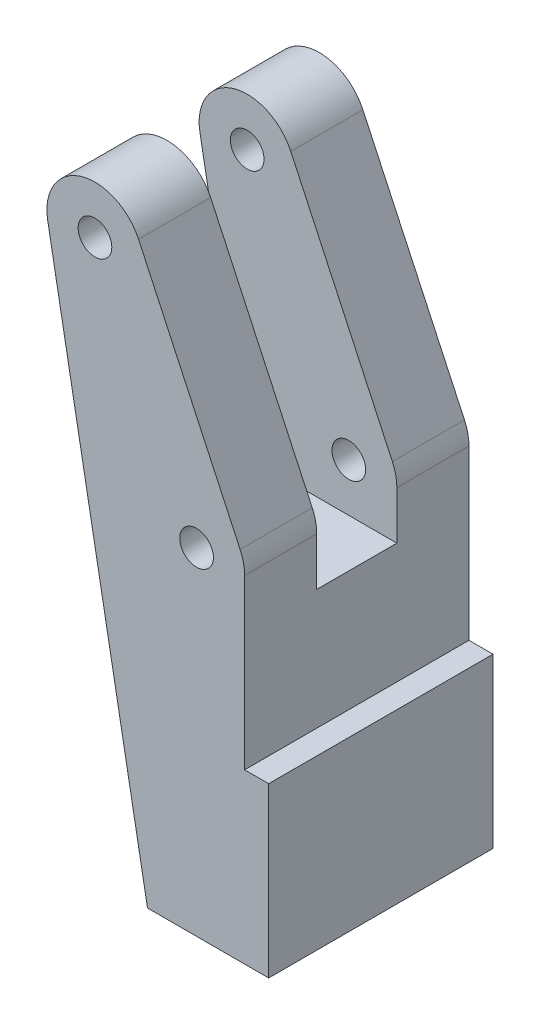
from build123d import *

# Parameters (mm, degrees)
SKETCH1_R           = 1.75
BOSS_EXTRUDE1_DEPTH = 7.5
BOSS_EXTRUDE2_DEPTH = 8.333333333
SKETCH3_R           = 1.75
BOSS_EXTRUDE4_DEPTH = 7.5
SKETCH4_W           = 23.333333333
SKETCH4_H           = 17.5
BOSS_EXTRUDE5_DEPTH = 2.5


with BuildPart() as part:
    # Sketch1 → Boss-Extrude1 (new body)
    with BuildSketch(Plane.XY):
        with BuildLine():
            Line((-6.033917608, 24.770785985), (4.531538935, 2.113091309))
            ThreePointArc((4.531538935, 2.113091309), (4.881480036, 1.08219807), (5, 0))
            Line((5, 0), (5, -35))
            Line((5, -35), (-5.1028501, -35))
            Line((-5.1028501, -35), (-15.483867589, 21.758121008))
            ThreePointArc((-15.483867589, 21.758121008), (-12.084158316, 27.421468907), (-6.033917608, 24.770785985))
        make_face()
        with Locations((-10.565456544, 22.657694676)):
            Circle(SKETCH1_R, mode=Mode.SUBTRACT)
        Circle(SKETCH1_R, mode=Mode.SUBTRACT)
    extrude(amount=BOSS_EXTRUDE1_DEPTH)

    # Sketch2 → Boss-Extrude2 (add)
    with BuildSketch(Plane.XY.offset(7.5)):
        Polygon((5, -5), (-10.589827455, -5), (-5.1028501, -35), (5, -35), align=None)
    extrude(amount=BOSS_EXTRUDE2_DEPTH)

    # Sketch3 → Boss-Extrude4 (add)
    with BuildSketch(Plane.XY.offset(15.833333333)):
        with BuildLine():
            Line((5, 0), (5, -35))
            Line((5, -35), (-5.1028501, -35))
            Line((-5.1028501, -35), (-15.483867589, 21.758121008))
            ThreePointArc((-15.483867589, 21.758121008), (-12.084158316, 27.421468907), (-6.033917608, 24.770785985))
            Line((-6.033917608, 24.770785985), (4.531538935, 2.113091309))
            ThreePointArc((4.531538935, 2.113091309), (4.881480036, 1.08219807), (5, 0))
        make_face()
        Circle(SKETCH3_R, mode=Mode.SUBTRACT)
        with Locations((-10.565456544, 22.657694676)):
            Circle(SKETCH3_R, mode=Mode.SUBTRACT)
    extrude(amount=BOSS_EXTRUDE4_DEPTH)

    # Sketch4 → Boss-Extrude5 (add)
    with BuildSketch(Plane(origin=(5, 0, 0), x_dir=(0, 0, -1), z_dir=(1, 0, 0))):
        with Locations((-11.666666667, -26.25)):
            Rectangle(SKETCH4_W, SKETCH4_H)
    extrude(amount=BOSS_EXTRUDE5_DEPTH)


solid = part.part
